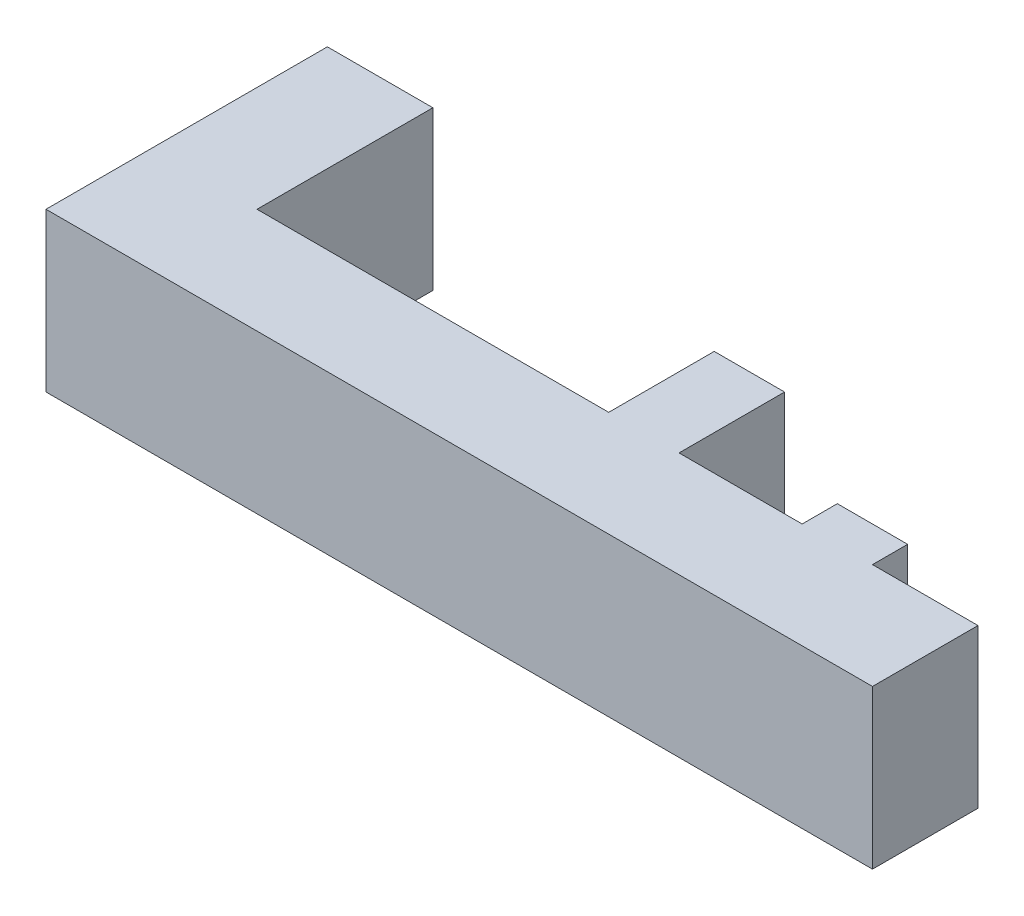
from build123d import *

# Parameters (mm, degrees)
SALIENTE_EXTRUIR1_DEPTH = 4.5


with BuildPart() as part:
    # Croquis1 → Saliente-Extruir1 (new body)
    with BuildSketch(Plane(origin=(0, 0, 0), x_dir=(1, 0, 0), z_dir=(0, 1, 0))):
        Polygon((13, 6), (13, 3), (3, 3), (3, 8), (0, 8), (0, 0), (23.5, 0), (23.5, 3), (20.5, 3), (20.5, 4), (18.5, 4), (18.5, 3), (15, 3), (15, 6), align=None)
    extrude(amount=SALIENTE_EXTRUIR1_DEPTH)


solid = part.part
